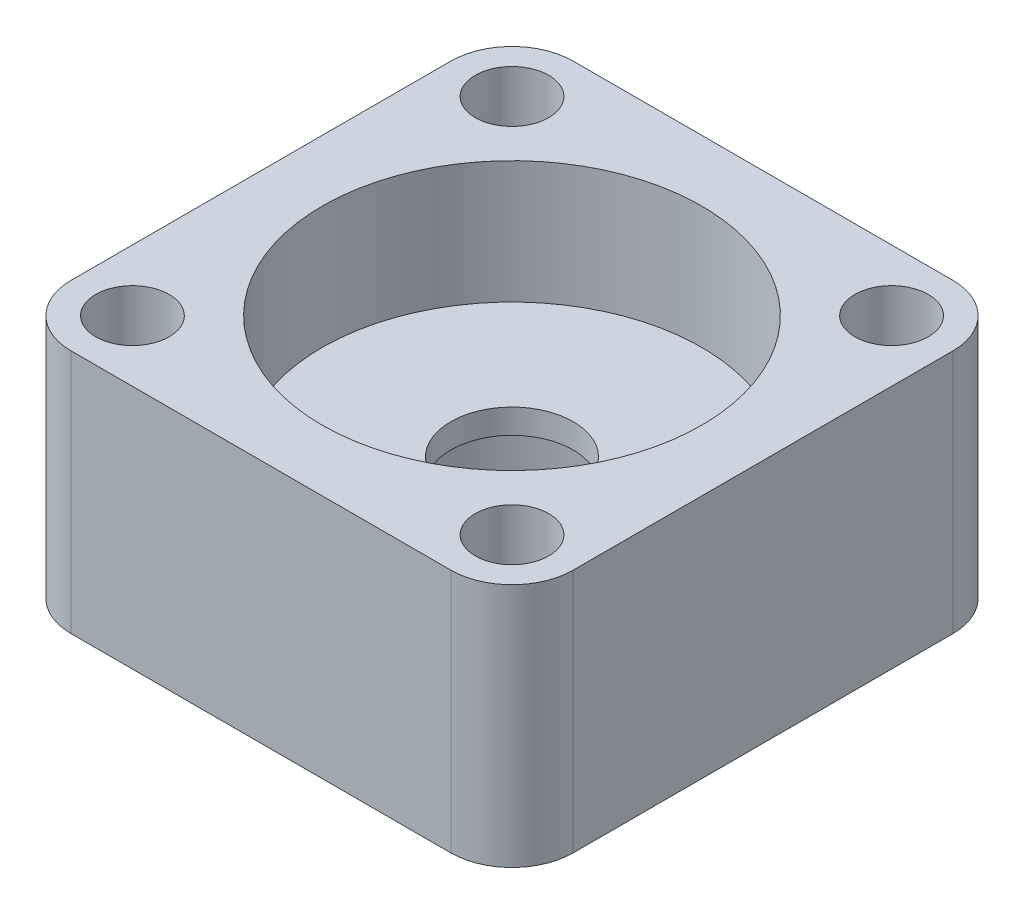
from build123d import *

# Parameters (mm, degrees)
SKETCH1_R           = 11
SKETCH1_R_2         = 1.75
BOSS_EXTRUDE1_DEPTH = 8
SKETCH2_R           = 1.75
SKETCH2_R_2         = 5
BOSS_EXTRUDE2_DEPTH = 2
SKETCH3_R           = 1.75
SKETCH3_R_2         = 15.5
BOSS_EXTRUDE3_DEPTH = 10
SKETCH4_R           = 3
CUT_EXTRUDE1_DEPTH  = 15


with BuildPart() as part:
    # Sketch1 → Boss-Extrude1 (new body)
    with BuildSketch(Plane(origin=(0, 0, 0), x_dir=(1, 0, 0), z_dir=(0, 1, 0))):
        with BuildLine():
            Line((-15.5, 20.5), (15.5, 20.5))
            ThreePointArc((15.5, 20.5), (19.035533906, 19.035533906), (20.5, 15.5))
            Line((20.5, 15.5), (20.5, -15.5))
            ThreePointArc((20.5, -15.5), (19.035533906, -19.035533906), (15.5, -20.5))
            Line((15.5, -20.5), (-15.5, -20.5))
            ThreePointArc((-15.5, -20.5), (-19.035533906, -19.035533906), (-20.5, -15.5))
            Line((-20.5, -15.5), (-20.5, 15.5))
            ThreePointArc((-20.5, 15.5), (-19.035533906, 19.035533906), (-15.5, 20.5))
        make_face()
        Circle(SKETCH1_R, mode=Mode.SUBTRACT)
        with Locations((-15.5, 15.5)):
            Circle(SKETCH1_R_2, mode=Mode.SUBTRACT)
        with Locations((15.5, 15.5)):
            Circle(SKETCH1_R_2, mode=Mode.SUBTRACT)
        with Locations((15.5, -15.5)):
            Circle(SKETCH1_R_2, mode=Mode.SUBTRACT)
        with Locations((-15.5, -15.5)):
            Circle(SKETCH1_R_2, mode=Mode.SUBTRACT)
    extrude(amount=BOSS_EXTRUDE1_DEPTH)

    # Sketch2 → Boss-Extrude2 (add)
    with BuildSketch(Plane(origin=(0, 8, 0), x_dir=(1, 0, 0), z_dir=(0, 1, 0))):
        with BuildLine():
            Line((-20.5, 15.5), (-20.5, -15.5))
            ThreePointArc((-20.5, -15.5), (-19.035533906, -19.035533906), (-15.5, -20.5))
            Line((-15.5, -20.5), (15.5, -20.5))
            ThreePointArc((15.5, -20.5), (19.035533906, -19.035533906), (20.5, -15.5))
            Line((20.5, -15.5), (20.5, 15.5))
            ThreePointArc((20.5, 15.5), (19.035533906, 19.035533906), (15.5, 20.5))
            Line((15.5, 20.5), (-15.5, 20.5))
            ThreePointArc((-15.5, 20.5), (-19.035533906, 19.035533906), (-20.5, 15.5))
        make_face()
        with Locations((15.5, 15.5)):
            Circle(SKETCH2_R, mode=Mode.SUBTRACT)
        with Locations((15.5, -15.5)):
            Circle(SKETCH2_R, mode=Mode.SUBTRACT)
        with Locations((-15.5, 15.5)):
            Circle(SKETCH2_R, mode=Mode.SUBTRACT)
        Circle(SKETCH2_R_2, mode=Mode.SUBTRACT)
        with Locations((-15.5, -15.5)):
            Circle(SKETCH2_R, mode=Mode.SUBTRACT)
    extrude(amount=BOSS_EXTRUDE2_DEPTH)

    # Sketch3 → Boss-Extrude3 (add)
    with BuildSketch(Plane(origin=(0, 10, 0), x_dir=(1, 0, 0), z_dir=(0, 1, 0))):
        with BuildLine():
            Line((-20.5, 15.5), (-20.5, -15.5))
            ThreePointArc((-20.5, -15.5), (-19.035533906, -19.035533906), (-15.5, -20.5))
            Line((-15.5, -20.5), (15.5, -20.5))
            ThreePointArc((15.5, -20.5), (19.035533906, -19.035533906), (20.5, -15.5))
            Line((20.5, -15.5), (20.5, 15.5))
            ThreePointArc((20.5, 15.5), (19.035533906, 19.035533906), (15.5, 20.5))
            Line((15.5, 20.5), (-15.5, 20.5))
            ThreePointArc((-15.5, 20.5), (-19.035533906, 19.035533906), (-20.5, 15.5))
        make_face()
        with Locations((15.5, 15.5)):
            Circle(SKETCH3_R, mode=Mode.SUBTRACT)
        with Locations((15.5, -15.5)):
            Circle(SKETCH3_R, mode=Mode.SUBTRACT)
        with Locations((-15.5, -15.5)):
            Circle(SKETCH3_R, mode=Mode.SUBTRACT)
        with Locations((-15.5, 15.5)):
            Circle(SKETCH3_R, mode=Mode.SUBTRACT)
        Circle(SKETCH3_R_2, mode=Mode.SUBTRACT)
    extrude(amount=BOSS_EXTRUDE3_DEPTH)

    # Sketch4 → Cut-Extrude1 (cut)
    with BuildSketch(Plane(origin=(0, 20, 0), x_dir=(1, 0, 0), z_dir=(0, 1, 0))):
        with Locations((-15.5, 15.5)):
            Circle(SKETCH4_R)
        with Locations((15.5, 15.5)):
            Circle(SKETCH4_R)
        with Locations((15.5, -15.5)):
            Circle(SKETCH4_R)
        with Locations((-15.5, -15.5)):
            Circle(SKETCH4_R)
    extrude(amount=-CUT_EXTRUDE1_DEPTH, mode=Mode.SUBTRACT)


solid = part.part
